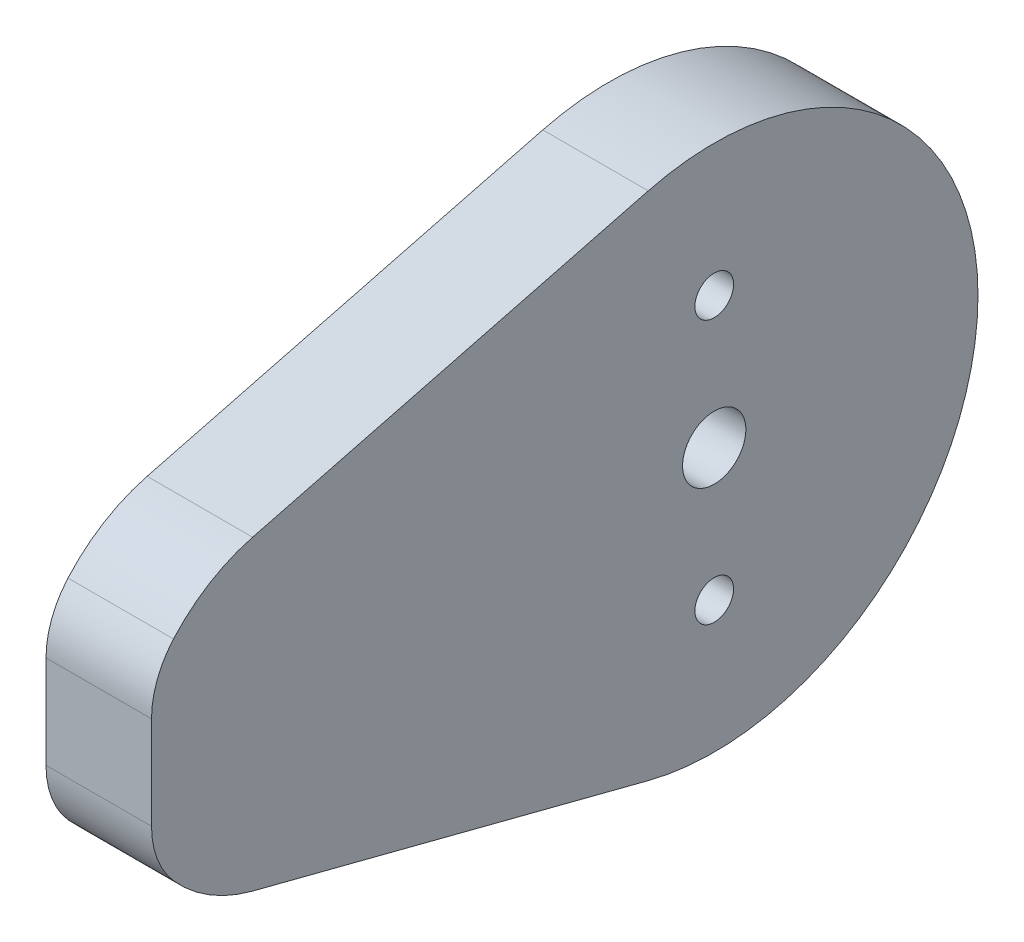
from build123d import *

# Parameters (mm, degrees)
ESQUISSE1_R        = 1.1
ESQUISSE1_R_2      = 1.8
BOSS_EXTRU_1_DEPTH = 6


with BuildPart() as part:
    # Esquisse1 → Boss.-Extru.1 (new body)
    with BuildSketch(Plane(origin=(0, 0, 0), x_dir=(0, 0, -1), z_dir=(1, 0, 0))):
        with BuildLine():
            Line((29.1, 44.045751311), (29.1, 38.754248689))
            ThreePointArc((29.1, 38.754248689), (29.422928267, 36.986481736), (30.35, 35.44705955))
            ThreePointArc((30.35, 35.44705955), (32.392967403, 33.729025868), (34.85, 32.685787471))
            Line((34.85, 32.685787471), (57.35, 26.876312452))
            ThreePointArc((57.35, 26.876312452), (76.1, 41.4), (57.35, 55.923687548))
            Line((57.35, 55.923687548), (34.85, 50.114212529))
            ThreePointArc((34.85, 50.114212529), (32.392967403, 49.070974132), (30.35, 47.35294045))
            ThreePointArc((30.35, 47.35294045), (29.422928267, 45.813518264), (29.1, 44.045751311))
        make_face()
        with Locations((61.1, 33.9)):
            Circle(ESQUISSE1_R, mode=Mode.SUBTRACT)
        with Locations(Location((61.1, 48.9, 0), (0, 0, 180))):  # turned: the seam where the file's is
            Circle(ESQUISSE1_R, mode=Mode.SUBTRACT)
        with Locations((61.1, 41.4)):
            Circle(ESQUISSE1_R_2, mode=Mode.SUBTRACT)
    extrude(amount=BOSS_EXTRU_1_DEPTH)


solid = part.part
